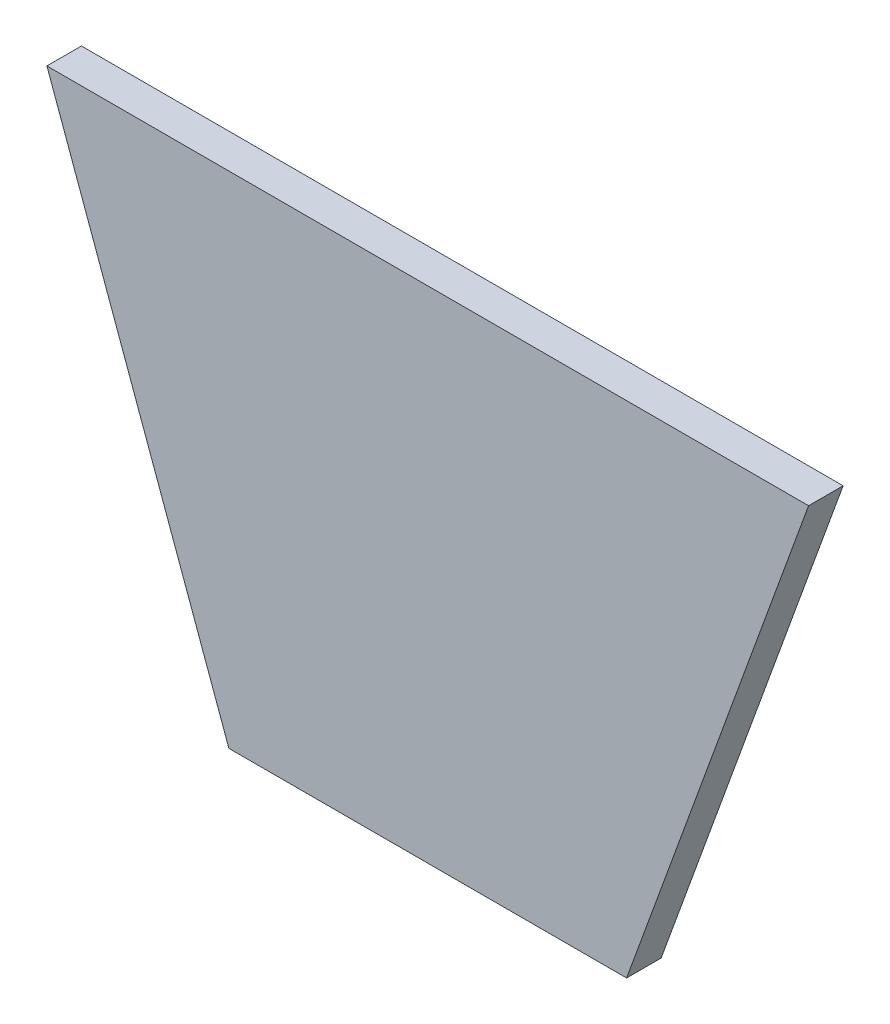
from build123d import *

# Parameters (mm, degrees)
BOSS_EXTRUDE1_DEPTH = 3


with BuildPart() as part:
    # Sketch1 → Boss-Extrude1 (new body)
    with BuildSketch(Plane.XY):
        Polygon((13.081238583, 148.026060427), (-53.081238583, 148.026060427), (-37.274192134, 104.59655724), (-2.725807866, 104.59655724), align=None)
    extrude(amount=BOSS_EXTRUDE1_DEPTH)


solid = part.part
